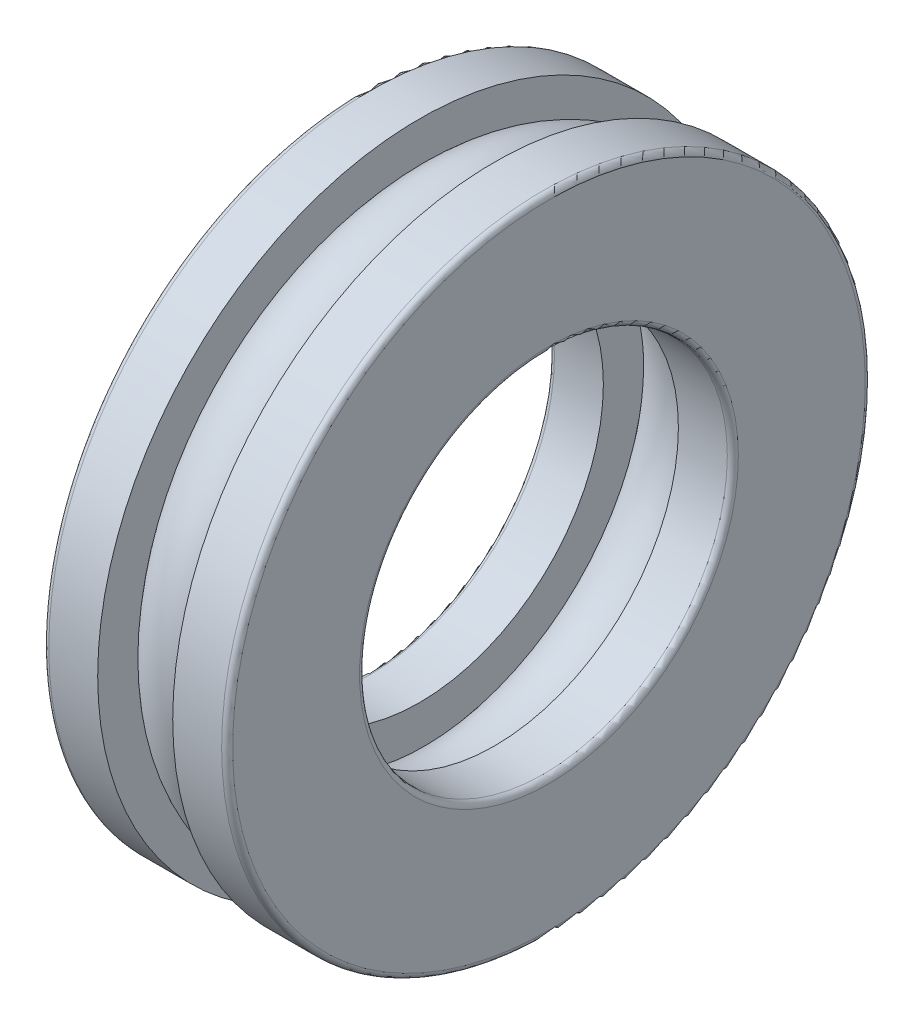
from build123d import *

# Parameters (mm, degrees)
BALSIMSKE_R = 2.55


with BuildPart() as part:
    # InnRacSke → Race (revolve)
    with BuildSketch(Plane.XY):
        with BuildLine():
            Line((-2.04, 12.262039987), (-2.04, 10))
            Line((-2.04, 10), (-4.7, 10))
            ThreePointArc((-4.7, 10), (-4.912132034, 10.087867966), (-5, 10.3))
            Line((-5, 10.3), (-5, 17.2))
            ThreePointArc((-5, 17.2), (-4.912132034, 17.412132034), (-4.7, 17.5))
            Line((-4.7, 17.5), (-2.04, 17.5))
            Line((-2.04, 17.5), (-2.04, 15.237960013))
            ThreePointArc((-2.04, 15.237960013), (-2.525, 13.75), (-2.04, 12.262039987))
        make_face()
    race = revolve(axis=Axis((-34.925, 0, 0), (1, 0, 0)))

    # BalSimSke → BallsSimplified (revolve)
    with BuildSketch(Plane.XY):
        with Locations((0, 13.75)):
            Circle(BALSIMSKE_R)
    revolve(axis=Axis((-25.4, 0, 0), (1, 0, 0)))

    # Mirror1: Race across plane
    add(race.mirror(Plane(origin=(0, 0, 0), x_dir=(0, 0, 1), z_dir=(1, 0, 0))))


solid = part.part
